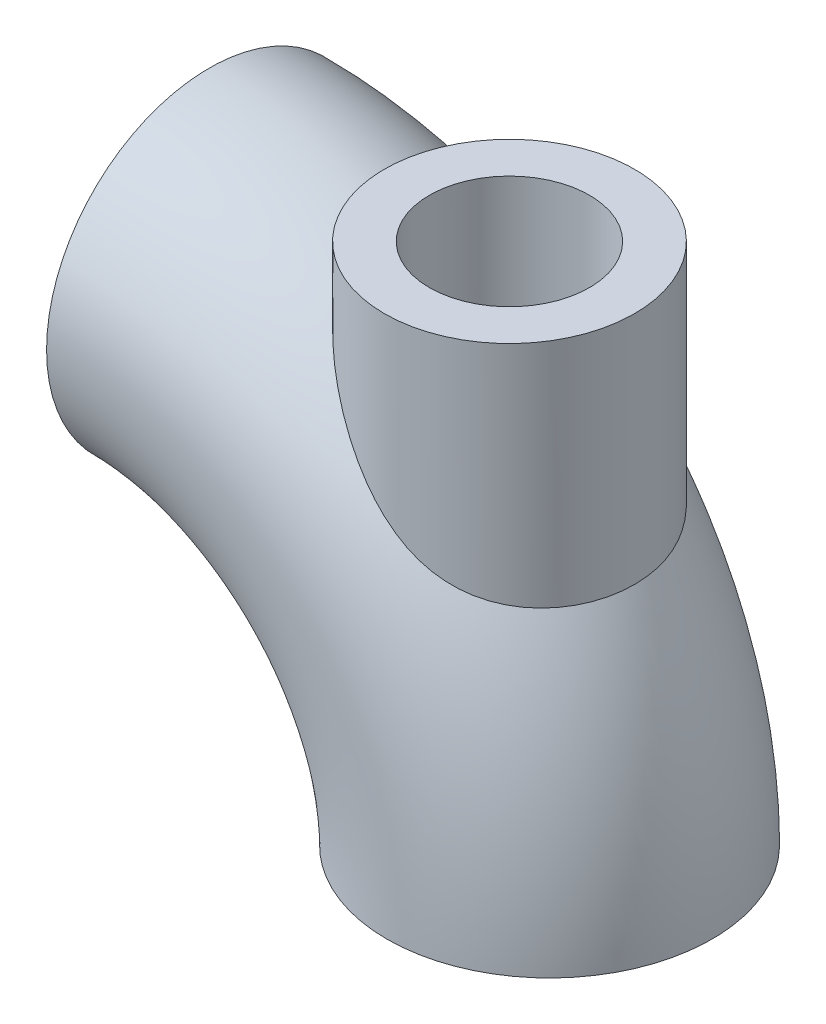
from build123d import *

# Parameters (mm, degrees)
SKETCH_1_R          = 32.5
SKETCH_1_R_2        = 20
EXTRUDE_3_REACH     = 102.5
SKETCH_5_R          = 25
SKETCH_9_R          = 16
CUT_EXTRUDE_3_DEPTH = 80


with BuildPart() as part:
    # 扫描1: sweep along a path in 草图2
    with BuildLine(Plane.XY) as sweep_1_path:
        ThreePointArc((0, 0), (-19.916738879, 48.083261121), (-68, 68))
    # 草图1 → 扫描1 (sweep)
    with BuildSketch(Plane(origin=(0, 0, 0), x_dir=(1, 0, 0), z_dir=(0, 1, 0))):
        Circle(SKETCH_1_R)
        Circle(SKETCH_1_R_2, mode=Mode.SUBTRACT)
    sweep(path=sweep_1_path.line)

    # 草图5 → 凸台-拉伸3 (add, up to next)
    with BuildSketch(Plane(origin=(0, 100.5, 0), x_dir=(1, 0, 0), z_dir=(0, 1, 0)), mode=Mode.PRIVATE) as extrude_3_sk1:
        with Locations((-8, 0)):
            Circle(SKETCH_5_R)
    extrude_3_tool1 = extrude(extrude_3_sk1.sketch, amount=-EXTRUDE_3_REACH, mode=Mode.PRIVATE) - part.part
    add(extrude_3_tool1.solids().sort_by_distance((-8, 100.5, 0))[0])

    # 草图9 → 切除-拉伸3 (cut)
    with BuildSketch(Plane(origin=(0, 100.5, 0), x_dir=(1, 0, 0), z_dir=(0, 1, 0))):
        with Locations((-8, 0)):
            Circle(SKETCH_9_R)
    extrude(amount=-CUT_EXTRUDE_3_DEPTH, mode=Mode.SUBTRACT)


solid = part.part
